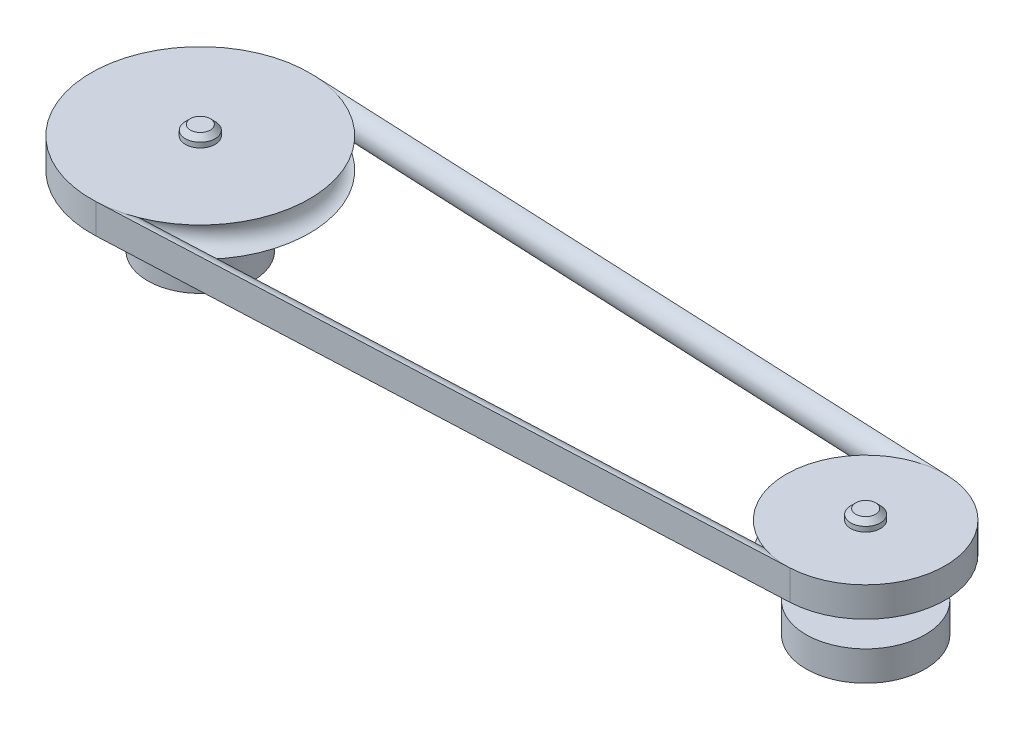
from build123d import *

# Parameters (mm, degrees)
SKETCH1_R             = 30
BOSS_EXTRUDE1_DEPTH   = 15
SKETCH1_R_2           = 26.5
BOSS_EXTRUDE1_2_DEPTH = 15
SKETCH2_R             = 7.5
BOSS_EXTRUDE2_DEPTH   = 40
SKETCH4_W             = 55
SKETCH4_H             = 15
SKETCH5_R             = 7.5
SKETCH6_W             = 40
SKETCH6_H             = 15
SKETCH7_R             = 7.5
CHAMFER1_SIZE         = 2.5
SKETCH10_R            = 7.5
CUT_EXTRUDE1_DEPTH    = 15
SKETCH11_R            = 7.5
CUT_EXTRUDE2_DEPTH    = 15


with BuildPart() as part:
    # Sketch1 → Boss-Extrude1 (new body)
    with BuildSketch(Plane(origin=(0, 0, 0), x_dir=(1, 0, 0), z_dir=(0, 1, 0))):
        with Locations((167.5, 0)):
            Circle(SKETCH1_R)
    extrude(amount=BOSS_EXTRUDE1_DEPTH)



with BuildPart() as body_2:
    # Sketch1 → Boss-Extrude1 2 (new body)
    with BuildSketch(Plane(origin=(0, 0, 0), x_dir=(1, 0, 0), z_dir=(0, 1, 0))):
        with Locations((-167.5, 0)):
            Circle(SKETCH1_R_2)
    extrude(amount=BOSS_EXTRUDE1_2_DEPTH)


with BuildPart() as part_1:
    add(part.part)

    add(body_2.part)  # Boss-Extrude2 merges body 2
    # Sketch2 → Boss-Extrude2 (add)
    with BuildSketch(Plane(origin=(0, 15, 0), x_dir=(1, 0, 0), z_dir=(0, 1, 0))):
        with Locations((-167.5, 0)):
            Circle(SKETCH2_R)
        with Locations((167.5, 0)):
            Circle(SKETCH2_R)
    extrude(amount=BOSS_EXTRUDE2_DEPTH)

    # Sketch4 → Revolve3 (revolve)
    with BuildSketch(Plane.XY):
        with Locations((-195, 42.5)):
            Rectangle(SKETCH4_W, SKETCH4_H)
    revolve(axis=Axis((-167.5, 55, 0), (0, -1, 0)))

    # Sketch5 → Cut-Revolve1 (revolve, cut)
    with BuildSketch(Plane.XY):
        with Locations((-222.5, 42.5)):
            Circle(SKETCH5_R)
    revolve(axis=Axis((-167.5, 55, 0), (0, 1, 0)), mode=Mode.SUBTRACT)

    # Sketch6 → Revolve4 (revolve)
    with BuildSketch(Plane.XY):
        with Locations((147.5, 42.5)):
            Rectangle(SKETCH6_W, SKETCH6_H)
    revolve(axis=Axis((167.5, 55, 0), (0, 1, 0)))

    # Sketch7 → Cut-Revolve2 (revolve, cut)
    with BuildSketch(Plane.XY):
        with Locations((127.5, 42.5)):
            Circle(SKETCH7_R)
    revolve(axis=Axis((167.5, 55, 0), (0, -1, 0)), mode=Mode.SUBTRACT)

    # Sweep1: sweep along a path in Sketch8
    with BuildLine(Plane(origin=(0, 42.5, 0), x_dir=(1, 0, 0), z_dir=(0, 1, 0))) as sweep1_path:
        Line((168.955223881, 32.467404015), (-165.373134328, 47.452359714))
        ThreePointArc((-165.373134328, 47.452359714), (-215, 0), (-165.373134328, -47.452359714))
        Line((-165.373134328, -47.452359714), (168.955223881, -32.467404015))
        ThreePointArc((168.955223881, -32.467404015), (200, 0), (168.955223881, 32.467404015))
    # Sketch9 → Sweep1 (sweep)
    with BuildSketch(Plane(origin=(-165.373134328, 42.5, 47.452359714), x_dir=(-0.044776119, 0, -0.998997047), z_dir=(0.998997047, 0, -0.044776119))):
        with BuildLine():
            Line((-7.5, 7.5), (-7.5, -7.5))
            ThreePointArc((-7.5, -7.5), (0, 0), (-7.5, 7.5))
        make_face()
    sweep(path=sweep1_path.line)

    # Chamfer1
    chamfer1_edges = [part_1.edges().sort_by_distance(p)[0] for p in [
        (160, 55, 0),
        (-175, 55, 0),
    ]]
    chamfer(chamfer1_edges, length=CHAMFER1_SIZE)

    # Sketch10 → Cut-Extrude1 (cut)
    with BuildSketch(Plane.XZ):
        with Locations((-167.5, 0)):
            Circle(SKETCH10_R)
    extrude(amount=-CUT_EXTRUDE1_DEPTH, mode=Mode.SUBTRACT)

    # Sketch11 → Cut-Extrude2 (cut)
    with BuildSketch(Plane.XZ):
        with Locations((167.5, 0)):
            Circle(SKETCH11_R)
    extrude(amount=-CUT_EXTRUDE2_DEPTH, mode=Mode.SUBTRACT)


solid = part_1.part
